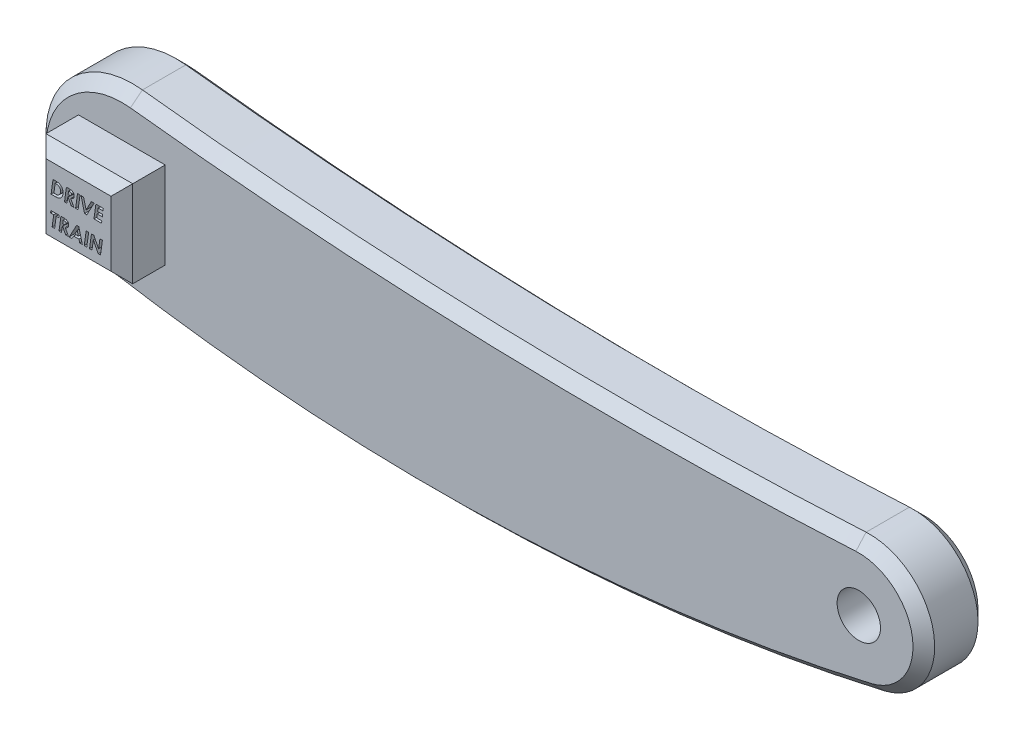
from build123d import *

# Parameters (mm, degrees)
BOSS_EXTRUDE1_DEPTH = 7.5
CHAMFER1_SIZE       = 2.5
SKETCH3_W           = 20
SKETCH3_H           = 20
BOSS_EXTRUDE2_DEPTH = 10
CUT_EXTRUDE1_DEPTH  = 2.5
CHAMFER4_SIZE       = 2.5
SKETCH5_R           = 5
CUT_EXTRUDE2_DEPTH  = 10
SKETCH6_R           = 5
BOSS_EXTRUDE3_DEPTH = 10


with BuildPart() as part:
    # Sketch2 → Boss-Extrude1 (new body, symmetric)
    with BuildSketch(Plane.XY):
        with BuildLine():
            ThreePointArc((-82.746539792, 19.872642429), (-104.801791361, 2.808746854), (-88.361833105, -19.715427415))
            ThreePointArc((-88.361833105, -19.715427415), (0.256800738, -25.931146508), (88.369675456, -14.61660998))
            ThreePointArc((88.369675456, -14.61660998), (99.852333231, 2.099570811), (84.186105477, 14.977902914))
            ThreePointArc((84.186105477, 14.977902914), (0.617423728, 13.934366249), (-82.746539792, 19.872642429))
        make_face()
    extrude(amount=BOSS_EXTRUDE1_DEPTH, both=True)

    # Chamfer1
    chamfer1_edges = [part.edges().sort_by_distance(p)[0] for p in [
        (99.852333231, 2.099570811, 7.5),
        (0.617423728, 13.934366249, 7.5),
        (-104.801791361, 2.808746854, 7.5),
        (0.256800738, -25.931146508, 7.5),
        (-104.801791361, 2.808746854, -7.5),
        (0.617423728, 13.934366249, -7.5),
        (99.852333231, 2.099570811, -7.5),
        (0.256800738, -25.931146508, -7.5),
    ]]
    chamfer(chamfer1_edges, length=CHAMFER1_SIZE)

    # Sketch3 → Boss-Extrude2 (add)
    with BuildSketch(Plane.XY.offset(7.5)):
        with Locations((-85, 0)):
            Rectangle(SKETCH3_W, SKETCH3_H)
    extrude(amount=BOSS_EXTRUDE2_DEPTH)

    # Sketch4 → Cut-Extrude1 (cut)
    with BuildSketch(Plane.XY.offset(17.5)):
        with BuildLine():
            Line((-90.88574281, 4.175), (-90.384560919, 4.175))
            add(Edge.make_bspline(
                [(-90.384560919, 4.175), (-90.327735394, 4.174530671), (-90.217845864, 4.17362308), (-90.058486764, 4.166139764), (-89.910587671, 4.152931459), (-89.773877962, 4.134650247), (-89.648346521, 4.11132667), (-89.533945406, 4.083084757), (-89.430560596, 4.049673665), (-89.337904009, 4.009529333), (-89.252589255, 3.964481615), (-89.172637614, 3.913079993), (-89.096672048, 3.855966422), (-89.024180278, 3.793502281), (-88.956631739, 3.724315519), (-88.893075843, 3.6491354), (-88.833269316, 3.568124899), (-88.777413922, 3.482125021), (-88.727171487, 3.391196254), (-88.683280844, 3.296157646), (-88.645598021, 3.197910516), (-88.615793035, 3.095915541), (-88.592231302, 2.990751045), (-88.575103333, 2.882007068), (-88.564647831, 2.769819906), (-88.563557975, 2.693949556), (-88.563006432, 2.655553886)],
                knots=[0, 0, 0, 0, 0.000170472, 0.000329659, 0.000478452, 0.000615804, 0.00074329, 0.000861297, 0.000969101, 0.001068816, 0.001163845, 0.001258235, 0.001353638, 0.001448771, 0.001545018, 0.001643393, 0.001743886, 0.001846913, 0.001950819, 0.002055254, 0.002160737, 0.00226619, 0.002373739, 0.002483845, 0.002596246, 0.002711409, 0.002711409, 0.002711409, 0.002711409], degree=3))
            add(Edge.make_bspline(
                [(-88.563006432, 2.655553886), (-88.563781385, 2.615885002), (-88.565321713, 2.537037553), (-88.576374236, 2.42019556), (-88.594248383, 2.305719765), (-88.618886009, 2.193649953), (-88.651334594, 2.08394142), (-88.691850184, 1.9771722), (-88.73798273, 1.872274369), (-88.792194433, 1.771405237), (-88.850658351, 1.674555335), (-88.913956055, 1.583996874), (-88.980344962, 1.49982759), (-89.051494423, 1.423202193), (-89.126037757, 1.35302874), (-89.204002644, 1.289308847), (-89.286230157, 1.232926402), (-89.372627804, 1.182879724), (-89.46549579, 1.139009731), (-89.566255824, 1.101845537), (-89.675217574, 1.069903728), (-89.792902569, 1.044967618), (-89.918749411, 1.024610926), (-90.053116994, 1.010030562), (-90.195990024, 1.002048709), (-90.294024807, 1.000696235), (-90.344491808, 1)],
                knots=[0, 0, 0, 0, 0.000118997, 0.000236522, 0.000351754, 0.000466408, 0.000580511, 0.000694628, 0.000808801, 0.000924033, 0.00103791, 0.001148007, 0.001255283, 0.00135925, 0.001461388, 0.001562211, 0.001661004, 0.001760168, 0.001861453, 0.001968721, 0.002082034, 0.002201795, 0.00232936, 0.002464355, 0.002607063, 0.002758468, 0.002758468, 0.002758468, 0.002758468], degree=3))
            Line((-90.344491808, 1), (-91.330955149, 1))
            Line((-91.330955149, 1), (-90.88574281, 4.175))
        make_face()
        with BuildLine():
            Line((-90.385196936, 3.645833333), (-90.681581151, 1.529166667))
            Line((-90.681581151, 1.529166667), (-90.476147457, 1.529166667))
            add(Edge.make_bspline(
                [(-90.476147457, 1.529166667), (-90.437981088, 1.529362145), (-90.364596034, 1.529738006), (-90.258589005, 1.533945755), (-90.1607312, 1.538954952), (-90.071073232, 1.54825638), (-89.989287497, 1.558606348), (-89.91592957, 1.572090496), (-89.85015571, 1.586584131), (-89.81013843, 1.600269326), (-89.791156472, 1.606760817)],
                knots=[0, 0, 0, 0, 0.00011449, 0.000220138, 0.000318252, 0.000408371, 0.000490497, 0.000565474, 0.000632119, 0.000692259, 0.000692259, 0.000692259, 0.000692259], degree=3))
            add(Edge.make_bspline(
                [(-89.791156472, 1.606760817), (-89.766766837, 1.616240243), (-89.718314582, 1.635071995), (-89.649983523, 1.671703485), (-89.58368518, 1.710528519), (-89.522318638, 1.756195865), (-89.463708607, 1.80576885), (-89.410199776, 1.861365441), (-89.359194402, 1.920940774), (-89.312500198, 1.985642319), (-89.269812574, 2.0544323), (-89.233459949, 2.12784875), (-89.202070349, 2.204916146), (-89.176935283, 2.28627137), (-89.15701987, 2.371272082), (-89.143414003, 2.460170657), (-89.133914946, 2.552949282), (-89.133227926, 2.616307653), (-89.132878226, 2.648557692)],
                knots=[0, 0, 0, 0, 7.8426e-05, 0.000155801, 0.000232264, 0.000308718, 0.000384948, 0.000462307, 0.000539917, 0.000620065, 0.00070144, 0.000782505, 0.000865533, 0.000950826, 0.001037684, 0.001127191, 0.001220475, 0.001317184, 0.001317184, 0.001317184, 0.001317184], degree=3))
            add(Edge.make_bspline(
                [(-89.132878226, 2.648557692), (-89.13324366, 2.675066943), (-89.133957881, 2.726877788), (-89.139569982, 2.802951435), (-89.149971865, 2.875739398), (-89.163585926, 2.945282361), (-89.181680102, 3.011519571), (-89.203241538, 3.074437184), (-89.228360056, 3.134490755), (-89.268560378, 3.208566062), (-89.325862699, 3.294988832), (-89.409569363, 3.386334974), (-89.50684336, 3.464368938), (-89.5975127, 3.518901695), (-89.676640747, 3.556215831), (-89.741626028, 3.5801089), (-89.811299788, 3.600619337), (-89.885782617, 3.616681145), (-89.964635641, 3.630480935), (-90.048397944, 3.638755025), (-90.136847143, 3.644883577), (-90.197559741, 3.645511094), (-90.2287366, 3.645833333)],
                knots=[0, 0, 0, 0, 7.9525e-05, 0.000155427, 0.000228644, 0.000299991, 0.000367879, 0.000434454, 0.000499428, 0.00056288, 0.000687066, 0.000809513, 0.00093298, 0.001059945, 0.001125956, 0.001195186, 0.001267437, 0.001343667, 0.001423656, 0.001507449, 0.00159604, 0.001689554, 0.001689554, 0.001689554, 0.001689554], degree=3))
            Line((-90.2287366, 3.645833333), (-90.385196936, 3.645833333))
        make_face(mode=Mode.SUBTRACT)
        with BuildLine():
            Line((-87.792153066, 4.175), (-87.240725782, 4.175))
            add(Edge.make_bspline(
                [(-87.240725782, 4.175), (-87.199803917, 4.17483277), (-87.12090164, 4.174510331), (-87.0074376, 4.169925244), (-86.903296913, 4.16300776), (-86.808603409, 4.15387877), (-86.723278027, 4.141212808), (-86.647498208, 4.126004783), (-86.580779928, 4.109068528), (-86.540769211, 4.093330255), (-86.522025863, 4.085957532)],
                knots=[0, 0, 0, 0, 0.000122758, 0.000236692, 0.000340599, 0.000435844, 0.000522015, 0.000599225, 0.000667726, 0.000728098, 0.000728098, 0.000728098, 0.000728098], degree=3))
            add(Edge.make_bspline(
                [(-86.522025863, 4.085957532), (-86.500923263, 4.076441268), (-86.45967102, 4.057838477), (-86.400558961, 4.026305605), (-86.345205119, 3.992336144), (-86.294526884, 3.954649334), (-86.247454788, 3.914832045), (-86.204280722, 3.872505562), (-86.165352327, 3.827020304), (-86.130261057, 3.779192111), (-86.099058052, 3.72908284), (-86.072273486, 3.676445389), (-86.049113336, 3.621725401), (-86.031027179, 3.564327425), (-86.015995408, 3.504940462), (-86.006273404, 3.443189818), (-85.999431516, 3.37928379), (-85.998869323, 3.33589995), (-85.998583355, 3.313832131)],
                knots=[0, 0, 0, 0, 6.9431e-05, 0.000135726, 0.000200852, 0.000264074, 0.000324989, 0.000385705, 0.00044524, 0.000504393, 0.000563519, 0.000622115, 0.000681412, 0.000741551, 0.000802483, 0.00086501, 0.000928929, 0.000995103, 0.000995103, 0.000995103, 0.000995103], degree=3))
            add(Edge.make_bspline(
                [(-85.998583355, 3.313832131), (-85.999255879, 3.286676162), (-86.000583552, 3.233065881), (-86.009258845, 3.154010309), (-86.025439345, 3.078148282), (-86.047229598, 3.005240825), (-86.074225972, 2.934815871), (-86.109041329, 2.868098868), (-86.149283552, 2.803927353), (-86.195759212, 2.743142655), (-86.247706952, 2.685187175), (-86.307688392, 2.633471657), (-86.372385273, 2.584518085), (-86.444455434, 2.541608582), (-86.521916768, 2.501749474), (-86.606536058, 2.467978416), (-86.696725133, 2.436812942), (-86.759964068, 2.421215056), (-86.792333355, 2.41323117)],
                knots=[0, 0, 0, 0, 8.1472e-05, 0.00016084, 0.000238178, 0.00031384, 0.000388957, 0.000464053, 0.000539224, 0.00061593, 0.000693367, 0.000772226, 0.000853128, 0.000936463, 0.001023502, 0.00111421, 0.001209545, 0.001309511, 0.001309511, 0.001309511, 0.001309511], degree=3))
            Line((-86.792333355, 2.41323117), (-86.059641047, 1))
            Line((-86.059641047, 1), (-86.696294693, 1))
            Line((-86.696294693, 1), (-87.413722577, 2.383974359))
            Line((-87.413722577, 2.383974359), (-87.467784076, 2.383974359))
            Line((-87.467784076, 2.383974359), (-87.66240547, 1))
            Line((-87.66240547, 1), (-88.237365406, 1))
            Line((-88.237365406, 1), (-87.792153066, 4.175))
        make_face()
        with BuildLine():
            add(Edge.make_bspline(
                [(-87.393370013, 2.913141026), (-87.352446917, 2.913521019), (-87.274171331, 2.914247849), (-87.16237832, 2.919303485), (-87.061566814, 2.927289554), (-86.972027555, 2.938702167), (-86.893525006, 2.952199159), (-86.82639265, 2.969049189), (-86.770322782, 2.989083569), (-86.724431039, 3.012842342), (-86.687255566, 3.040737459), (-86.655078597, 3.070505922), (-86.628285481, 3.10382842), (-86.60617876, 3.140145539), (-86.589128574, 3.179532553), (-86.576832754, 3.222256304), (-86.570034297, 3.268031926), (-86.56898918, 3.299606376), (-86.568455149, 3.315740184)],
                knots=[0, 0, 0, 0, 0.000122766, 0.000234821, 0.000335651, 0.000426058, 0.000505529, 0.000574484, 0.000633441, 0.000683799, 0.000728831, 0.000772476, 0.000814989, 0.000856657, 0.000899667, 0.000943349, 0.000989674, 0.001038078, 0.001038078, 0.001038078, 0.001038078], degree=3))
            add(Edge.make_bspline(
                [(-86.568455149, 3.315740184), (-86.569146431, 3.334033594), (-86.570487423, 3.3695203), (-86.582086454, 3.420631391), (-86.601920398, 3.466996092), (-86.629794304, 3.508171137), (-86.664579439, 3.544477252), (-86.707015398, 3.574379527), (-86.756617278, 3.59791837), (-86.803082408, 3.61346977), (-86.847064089, 3.622477539), (-86.88806349, 3.628529554), (-86.936605636, 3.634369532), (-86.992836539, 3.638688012), (-87.056688601, 3.641544605), (-87.128129315, 3.644320401), (-87.207014555, 3.64530749), (-87.262138519, 3.645652746), (-87.290971175, 3.645833333)],
                knots=[0, 0, 0, 0, 5.483e-05, 0.000106364, 0.000156221, 0.00020526, 0.000254739, 0.000306272, 0.000360034, 0.000418964, 0.000452769, 0.000494596, 0.000543271, 0.000599418, 0.000663734, 0.000735014, 0.00081389, 0.000900391, 0.000900391, 0.000900391, 0.000900391], degree=3))
            Line((-87.290971175, 3.645833333), (-87.393370013, 2.913141026))
        make_face(mode=Mode.SUBTRACT)
        Polygon((-85.227729989, 4.175), (-84.652770053, 4.175), (-85.097982393, 1), (-85.672942329, 1), align=None)
        Polygon((-84.409811319, 4.175), (-83.823403066, 4.175), (-83.250987201, 1.882792468), (-82.034285478, 4.175), (-81.394451744, 4.175), (-83.080534476, 1), (-83.616697337, 1), align=None)
        Polygon((-80.994396656, 4.175), (-79.282237201, 4.175), (-79.349019052, 3.645833333), (-80.493214765, 3.645833333), (-80.596249621, 2.913141026), (-79.441241608, 2.913141026), (-79.508659476, 2.383974359), (-80.670663683, 2.383974359), (-80.790234997, 1.529166667), (-79.616146456, 1.529166667), (-79.682928307, 1), (-81.439608996, 1), align=None)
        Polygon((-91.371660278, -2.279487179), (-89.458519252, -2.279487179), (-89.527209156, -2.808653846), (-90.14541829, -2.808653846), (-90.512400462, -5.454487179), (-91.08672438, -5.454487179), (-90.720378226, -2.808653846), (-91.444802305, -2.808653846), align=None)
        with BuildLine():
            Line((-89.05401204, -2.279487179), (-88.502584757, -2.279487179))
            add(Edge.make_bspline(
                [(-88.502584757, -2.279487179), (-88.461662891, -2.279654409), (-88.382760614, -2.279976849), (-88.269296574, -2.284561936), (-88.165155888, -2.291479419), (-88.070462383, -2.300608409), (-87.985137002, -2.313274372), (-87.909357182, -2.328482397), (-87.842638902, -2.345418652), (-87.802628185, -2.361156925), (-87.783884837, -2.368529647)],
                knots=[0, 0, 0, 0, 0.000122758, 0.000236692, 0.000340599, 0.000435844, 0.000522015, 0.000599225, 0.000667726, 0.000728098, 0.000728098, 0.000728098, 0.000728098], degree=3))
            add(Edge.make_bspline(
                [(-87.783884837, -2.368529647), (-87.762782237, -2.378045912), (-87.721529995, -2.396648703), (-87.662417936, -2.428181575), (-87.607064093, -2.462151036), (-87.556385858, -2.499837846), (-87.509313763, -2.539655135), (-87.466139697, -2.581981618), (-87.427211301, -2.627466875), (-87.392120031, -2.675295069), (-87.360917026, -2.72540434), (-87.33413246, -2.778041791), (-87.310972311, -2.832761779), (-87.292886153, -2.890159754), (-87.277854383, -2.949546718), (-87.268132378, -3.011297361), (-87.261290491, -3.075203389), (-87.260728297, -3.118587229), (-87.260442329, -3.140655048)],
                knots=[0, 0, 0, 0, 6.9431e-05, 0.000135726, 0.000200852, 0.000264074, 0.000324989, 0.000385705, 0.00044524, 0.000504393, 0.000563519, 0.000622115, 0.000681412, 0.000741551, 0.000802483, 0.00086501, 0.000928929, 0.000995103, 0.000995103, 0.000995103, 0.000995103], degree=3))
            add(Edge.make_bspline(
                [(-87.260442329, -3.140655048), (-87.261114854, -3.167811018), (-87.262442527, -3.221421299), (-87.27111782, -3.30047687), (-87.28729832, -3.376338898), (-87.309088573, -3.449246355), (-87.336084947, -3.519671308), (-87.370900303, -3.586388311), (-87.411142526, -3.650559827), (-87.457618186, -3.711344524), (-87.509565927, -3.769300004), (-87.569547366, -3.821015523), (-87.634244247, -3.869969094), (-87.706314408, -3.912878597), (-87.783775742, -3.952737705), (-87.868395033, -3.986508764), (-87.958584108, -4.017674238), (-88.021823043, -4.033272124), (-88.054192329, -4.04125601)],
                knots=[0, 0, 0, 0, 8.1472e-05, 0.00016084, 0.000238178, 0.00031384, 0.000388957, 0.000464053, 0.000539224, 0.00061593, 0.000693367, 0.000772226, 0.000853128, 0.000936463, 0.001023502, 0.00111421, 0.001209545, 0.001309511, 0.001309511, 0.001309511, 0.001309511], degree=3))
            Line((-88.054192329, -4.04125601), (-87.321500021, -5.454487179))
            Line((-87.321500021, -5.454487179), (-87.958153667, -5.454487179))
            Line((-87.958153667, -5.454487179), (-88.675581552, -4.070512821))
            Line((-88.675581552, -4.070512821), (-88.72964305, -4.070512821))
            Line((-88.72964305, -4.070512821), (-88.924264444, -5.454487179))
            Line((-88.924264444, -5.454487179), (-89.49922438, -5.454487179))
            Line((-89.49922438, -5.454487179), (-89.05401204, -2.279487179))
        make_face()
        with BuildLine():
            add(Edge.make_bspline(
                [(-88.655228988, -3.541346154), (-88.614305892, -3.540966161), (-88.536030305, -3.54023933), (-88.424237294, -3.535183694), (-88.323425789, -3.527197626), (-88.233886529, -3.515785012), (-88.155383981, -3.50228802), (-88.088251624, -3.48543799), (-88.032181757, -3.465403611), (-87.986290013, -3.441644837), (-87.949114541, -3.41374972), (-87.916937571, -3.383981258), (-87.890144456, -3.350658759), (-87.868037734, -3.31434164), (-87.850987548, -3.274954626), (-87.838691728, -3.232230876), (-87.831893272, -3.186455253), (-87.830848154, -3.154880804), (-87.830314124, -3.138746995)],
                knots=[0, 0, 0, 0, 0.000122766, 0.000234821, 0.000335651, 0.000426058, 0.000505529, 0.000574484, 0.000633441, 0.000683799, 0.000728831, 0.000772476, 0.000814989, 0.000856657, 0.000899667, 0.000943349, 0.000989674, 0.001038078, 0.001038078, 0.001038078, 0.001038078], degree=3))
            add(Edge.make_bspline(
                [(-87.830314124, -3.138746995), (-87.831005406, -3.120453586), (-87.832346397, -3.084966879), (-87.843945429, -3.033855789), (-87.863779373, -2.987491087), (-87.891653278, -2.946316043), (-87.926438414, -2.910009927), (-87.968874373, -2.880107653), (-88.018476253, -2.85656881), (-88.064941383, -2.841017409), (-88.108923064, -2.83200964), (-88.149922464, -2.825957626), (-88.19846461, -2.820117648), (-88.254695513, -2.815799168), (-88.318547576, -2.812942574), (-88.389988289, -2.810166779), (-88.46887353, -2.80917969), (-88.523997493, -2.808834433), (-88.552830149, -2.808653846)],
                knots=[0, 0, 0, 0, 5.483e-05, 0.000106364, 0.000156221, 0.00020526, 0.000254739, 0.000306272, 0.000360034, 0.000418964, 0.000452769, 0.000494596, 0.000543271, 0.000599418, 0.000663734, 0.000735014, 0.00081389, 0.000900391, 0.000900391, 0.000900391, 0.000900391], degree=3))
            Line((-88.552830149, -2.808653846), (-88.655228988, -3.541346154))
        make_face(mode=Mode.SUBTRACT)
        Polygon((-85.431891648, -2.279487179), (-84.931981792, -2.279487179), (-84.126147457, -5.454487179), (-84.71255571, -5.454487179), (-84.888096576, -4.7625), (-86.12578688, -4.7625), (-86.497221175, -5.454487179), (-87.138326944, -5.454487179), align=None)
        Polygon((-85.023568331, -4.233333333), (-85.285607593, -3.199804688), (-85.840850983, -4.233333333), align=None, mode=Mode.SUBTRACT)
        Polygon((-83.233178707, -2.279487179), (-82.658218771, -2.279487179), (-83.103431111, -5.454487179), (-83.678391047, -5.454487179), align=None)
        Polygon((-82.015840967, -2.279487179), (-81.480950141, -2.279487179), (-80.360923098, -4.43813101), (-80.058178707, -2.279487179), (-79.483218771, -2.279487179), (-79.927795093, -5.454487179), (-80.458233795, -5.454487179), (-81.582076944, -3.272310697), (-81.887365406, -5.454487179), (-82.462325342, -5.454487179), align=None)
    extrude(amount=-CUT_EXTRUDE1_DEPTH, mode=Mode.SUBTRACT)

    # Chamfer4
    chamfer4_edges = [part.edges().sort_by_distance(p)[0] for p in [
        (-75, 0, 17.5),
        (-85, 10, 17.5),
        (-95, 0, 17.5),
        (-85, -10, 17.5),
    ]]
    chamfer(chamfer4_edges, length=CHAMFER4_SIZE)

    # Sketch5 → Cut-Extrude2 (cut)
    with BuildSketch(Plane.XY.offset(7.5)):
        with Locations((85, 0)):
            Circle(SKETCH5_R)
    extrude(amount=-CUT_EXTRUDE2_DEPTH, mode=Mode.SUBTRACT)

    # Sketch6 → Boss-Extrude3 (add)
    with BuildSketch(Plane(origin=(0, 0, -7.5), x_dir=(-1, 0, 0), z_dir=(0, 0, -1))):
        with Locations((85, 0)):
            Circle(SKETCH6_R)
    extrude(amount=BOSS_EXTRUDE3_DEPTH)


solid = part.part
